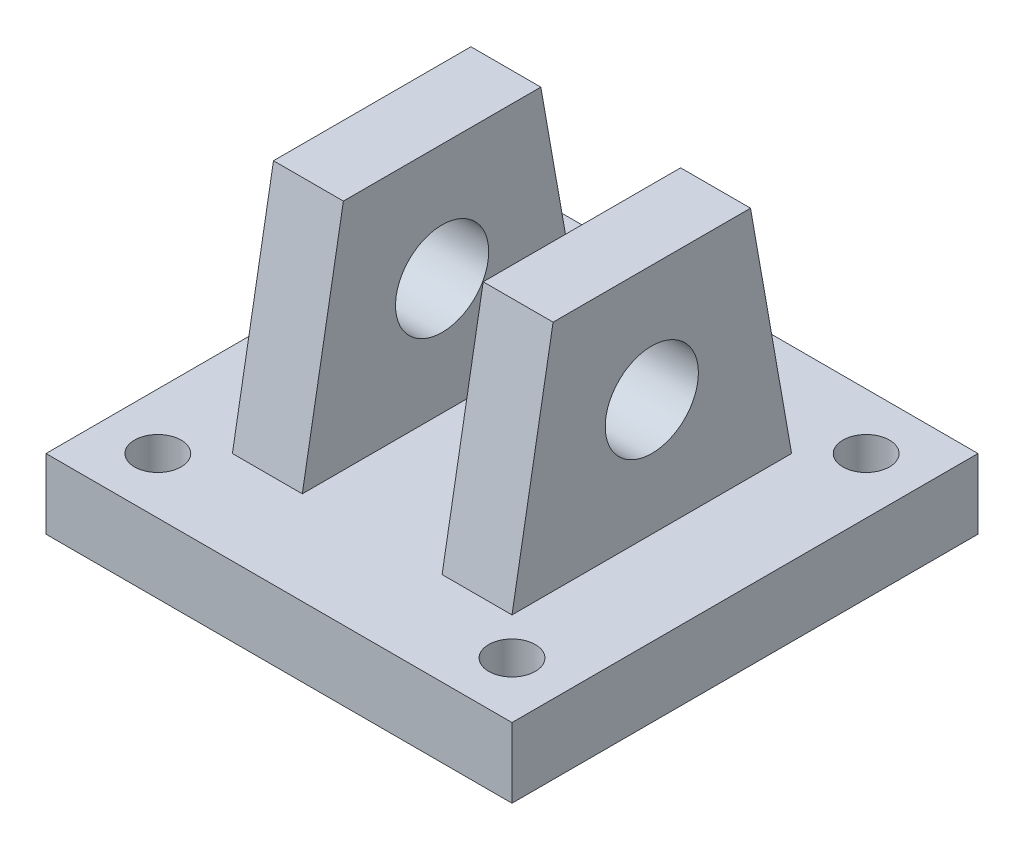
from build123d import *

# Parameters (mm, degrees)
SKETCH1_W          = 127
SKETCH1_H          = 127
EXTRUDE1_DEPTH     = 19.05
EXTRUDE2_DEPTH     = 38.1
SKETCH3_R          = 12.7
CUT_EXTRUDE1_DEPTH = 38.1
SKETCH4_W          = 38.1
SKETCH4_H          = 63.5
CUT_EXTRUDE2_DEPTH = 38.1
CUT_EXTRUDE3_REACH = 21.05
SKETCH5_R          = 6.35
CUT_EXTRUDE4_REACH = 21.05
SKETCH6_R          = 6.35
CUT_EXTRUDE5_REACH = 21.05
SKETCH8_R          = 6.35


with BuildPart() as part:
    # Sketch1 → Extrude1 (new body)
    with BuildSketch(Plane(origin=(0, 0, 0), x_dir=(1, 0, 0), z_dir=(0, 1, 0))):
        Rectangle(SKETCH1_W, SKETCH1_H)
    extrude(amount=-EXTRUDE1_DEPTH)

    # Sketch2 → Extrude2 (add, symmetric)
    with BuildSketch(Plane(origin=(0, 0, 0), x_dir=(0, 0, -1), z_dir=(1, 0, 0))):
        Polygon((38.1, 0), (26.903236725, 63.5), (-26.903236725, 63.5), (-38.1, 0), align=None)
    extrude(amount=EXTRUDE2_DEPTH, both=True)

    # Sketch3 → Cut-Extrude1 (cut, symmetric)
    with BuildSketch(Plane(origin=(0, 0, 0), x_dir=(0, 0, -1), z_dir=(1, 0, 0))):
        with Locations((0, 31.75)):
            Circle(SKETCH3_R)
    extrude(amount=CUT_EXTRUDE1_DEPTH, both=True, mode=Mode.SUBTRACT)

    # Sketch4 → Cut-Extrude2 (cut, symmetric)
    with BuildSketch(Plane.XY):
        with Locations((0, 31.75)):
            Rectangle(SKETCH4_W, SKETCH4_H)
    extrude(amount=CUT_EXTRUDE2_DEPTH, both=True, mode=Mode.SUBTRACT)

    # Sketch5 → Cut-Extrude3 (cut, up to next)
    with BuildSketch(Plane(origin=(0, 0, 0), x_dir=(1, 0, 0), z_dir=(0, 1, 0)), mode=Mode.PRIVATE) as cut_extrude3_sk1:
        with Locations((-48.26, 48.26)):
            Circle(SKETCH5_R)
    cut_extrude3_tool1 = extrude(cut_extrude3_sk1.sketch, amount=-CUT_EXTRUDE3_REACH, mode=Mode.PRIVATE) & part.part
    add(cut_extrude3_tool1.solids().sort_by_distance((-48.26, 0, -48.26))[0], mode=Mode.SUBTRACT)

    # Sketch6 → Cut-Extrude4 (cut, up to next)
    with BuildSketch(Plane(origin=(0, 0, 0), x_dir=(1, 0, 0), z_dir=(0, 1, 0)), mode=Mode.PRIVATE) as cut_extrude4_sk1:
        with Locations((48.26, 48.26)):
            Circle(SKETCH6_R)
    cut_extrude4_tool1 = extrude(cut_extrude4_sk1.sketch, amount=-CUT_EXTRUDE4_REACH, mode=Mode.PRIVATE) & part.part
    add(cut_extrude4_tool1.solids().sort_by_distance((48.26, 0, -48.26))[0], mode=Mode.SUBTRACT)

    # Sketch8 → Cut-Extrude5 (cut, up to next)
    with BuildSketch(Plane(origin=(0, 0, 0), x_dir=(1, 0, 0), z_dir=(0, 1, 0)), mode=Mode.PRIVATE) as cut_extrude5_sk1:
        with Locations((-48.26, -48.26)):
            Circle(SKETCH8_R)
    cut_extrude5_tool1 = extrude(cut_extrude5_sk1.sketch, amount=-CUT_EXTRUDE5_REACH, mode=Mode.PRIVATE) & part.part
    add(cut_extrude5_tool1.solids().sort_by_distance((-48.26, 0, 48.26))[0], mode=Mode.SUBTRACT)
    # Sketch8 → Cut-Extrude5 (cut, up to next)
    with BuildSketch(Plane(origin=(0, 0, 0), x_dir=(1, 0, 0), z_dir=(0, 1, 0)), mode=Mode.PRIVATE) as cut_extrude5_sk2:
        with Locations((48.26, -48.26)):
            Circle(SKETCH8_R)
    cut_extrude5_tool2 = extrude(cut_extrude5_sk2.sketch, amount=-CUT_EXTRUDE5_REACH, mode=Mode.PRIVATE) & part.part
    add(cut_extrude5_tool2.solids().sort_by_distance((48.26, 0, 48.26))[0], mode=Mode.SUBTRACT)


solid = part.part
